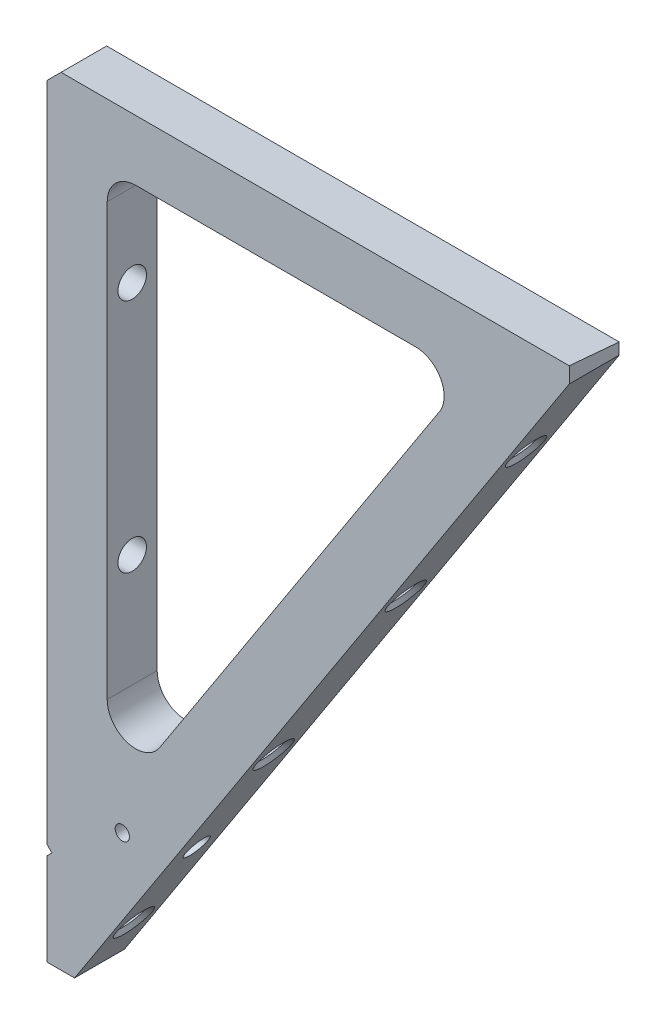
from build123d import *

# Parameters (mm, degrees)
BOSS_EXTRUDE1_DEPTH              = 11.1252
F_1_4_20_TAPPED_HOLE1_AT_2_COUNT = 2
F_1_4_20_TAPPED_HOLE1_AT_2_PITCH = 101.6
F_1_4_20_TAPPED_HOLE1_AT_3_COUNT = 2
F_1_4_20_TAPPED_HOLE1_AT_3_PITCH = 49.130736385
F_1_4_20_TAPPED_HOLE2_AT_2_COUNT = 2
F_1_4_20_TAPPED_HOLE2_AT_2_PITCH = 53.975
F_1_4_20_TAPPED_HOLE2_AT_3_COUNT = 2
F_1_4_20_TAPPED_HOLE2_AT_3_PITCH = 111.125
F_1_4_20_TAPPED_HOLE2_AT_4_COUNT = 2
F_1_4_20_TAPPED_HOLE2_AT_4_PITCH = 49.1998
CUT_EXTRUDE1_DEPTH               = 12.1252001
CHAMFER3_SIZE                    = 3.175
CUT_EXTRUDE2_DEPTH               = 119.608154476
CUT_EXTRUDE3_DEPTH               = 12.1252001
F_1_8_0_125_DIAMETER_HOLE1_D     = 3.175
CUT_EXTRUDE4_DEPTH               = 12.1252001


with BuildPart() as part:
    # Sketch1 → Boss-Extrude1 (new body)
    with BuildSketch(Plane.XY):
        Polygon((0, 0), (0, -182.6405415), (118.608154476, 0), align=None)
        with BuildLine():
            Line((19.802154476, -13.462), (82.118989682, -13.462))
            ThreePointArc((82.118989682, -13.462), (87.699478347, -16.782041872), (87.444547788, -23.270457872))
            Line((87.444547788, -23.270457872), (25.127712583, -119.229969062))
            ThreePointArc((25.127712583, -119.229969062), (17.998657037, -121.860016506), (13.452154476, -115.771511189))
            Line((13.452154476, -115.771511189), (13.452154476, -19.812))
            ThreePointArc((13.452154476, -19.812), (15.312026416, -15.321871939), (19.802154476, -13.462))
        make_face(mode=Mode.SUBTRACT)
    extrude(amount=BOSS_EXTRUDE1_DEPTH)

    # Sketch3 → 1/4-20 Tapped Hole1 (revolve, cut)
    with BuildSketch(Plane(origin=(0, -139.805902277, 5.5626), x_dir=(0, 0, 1), z_dir=(0, 1, 0))):
        Polygon((0, 0), (0, 32.217016902), (2.5527, 30.6832), (2.5527, 15.24), (3.175, 15.24), (3.175, 0.889), (4.064, 0), align=None)
    f_1_4_20_tapped_hole1 = revolve(axis=Axis((-6.35, -139.805902277, 5.5626), (1, 0, 0)), mode=Mode.SUBTRACT)

    # 1/4-20 Tapped Hole1 at 2: 1/4-20 Tapped Hole1 ×2
    with Locations(*[(0, i * F_1_4_20_TAPPED_HOLE1_AT_2_PITCH, 0) for i in range(1, F_1_4_20_TAPPED_HOLE1_AT_2_COUNT)]):
        add(f_1_4_20_tapped_hole1, mode=Mode.SUBTRACT)

    # 1/4-20 Tapped Hole1 at 3: 1/4-20 Tapped Hole1 ×2
    with Locations(*[(0, i * F_1_4_20_TAPPED_HOLE1_AT_3_PITCH, 0) for i in range(1, F_1_4_20_TAPPED_HOLE1_AT_3_COUNT)]):
        add(f_1_4_20_tapped_hole1, mode=Mode.SUBTRACT)

    # Sketch6 → 1/4-20 Tapped Hole2 (revolve, cut)
    with BuildSketch(Plane(origin=(74.349919226, -68.151705822, 5.5626), x_dir=(0.544639035, 0.838670568, 0), z_dir=(0, 0, 1))):
        Polygon((0, 0), (0, 19.517016902), (2.5527, 17.9832), (2.5527, 15.24), (3.175, 15.24), (3.175, 0.889), (4.064, 0), align=None)
    f_1_4_20_tapped_hole2 = revolve(axis=Axis((79.675477332, -71.610163694, 5.5626), (-0.838670568, 0.544639035, 0)), mode=Mode.SUBTRACT)

    # 1/4-20 Tapped Hole2 at 2: 1/4-20 Tapped Hole2 ×2
    with Locations(*[Vector(-0.544639035, -0.838670568, 0) * (i * F_1_4_20_TAPPED_HOLE2_AT_2_PITCH) for i in range(1, F_1_4_20_TAPPED_HOLE2_AT_2_COUNT)]):
        add(f_1_4_20_tapped_hole2, mode=Mode.SUBTRACT)

    # 1/4-20 Tapped Hole2 at 3: 1/4-20 Tapped Hole2 ×2
    with Locations(*[Vector(-0.544639035, -0.838670568, 0) * (i * F_1_4_20_TAPPED_HOLE2_AT_3_PITCH) for i in range(1, F_1_4_20_TAPPED_HOLE2_AT_3_COUNT)]):
        add(f_1_4_20_tapped_hole2, mode=Mode.SUBTRACT)

    # 1/4-20 Tapped Hole2 at 4: 1/4-20 Tapped Hole2 ×2
    with Locations(*[Vector(0.544639035, 0.838670568, 0) * (i * F_1_4_20_TAPPED_HOLE2_AT_4_PITCH) for i in range(1, F_1_4_20_TAPPED_HOLE2_AT_4_COUNT)]):
        add(f_1_4_20_tapped_hole2, mode=Mode.SUBTRACT)

    # Sketch8 → Cut-Extrude1 (cut, through all)
    with BuildSketch(Plane.XY.offset(11.1252)):
        Polygon((0, -182.6405415), (0, -173.1155415), (6.185607325, -173.1155415), align=None)
    extrude(amount=-CUT_EXTRUDE1_DEPTH, mode=Mode.SUBTRACT)

    # Chamfer3
    chamfer3_edges = [part.edges().sort_by_distance(p)[0] for p in [
        (0, 0, 5.5626),
    ]]
    chamfer(chamfer3_edges, length=CHAMFER3_SIZE)

    # Sketch9 → Cut-Extrude2 (cut, through all)
    with BuildSketch(Plane.ZY):
        Polygon((11.1252, 0), (0, 0), (0, -0.973328879), align=None)
    extrude(amount=-CUT_EXTRUDE2_DEPTH, mode=Mode.SUBTRACT)

    # Sketch10 → Cut-Extrude3 (cut, through all)
    with BuildSketch(Plane.XY.offset(11.1252)):
        Polygon((118.608154476, 0), (116.322154476, 0), (116.322154476, -3.520131307), align=None)
    extrude(amount=-CUT_EXTRUDE3_DEPTH, mode=Mode.SUBTRACT)

    # 1/8 (0.125) Diameter Hole1 (through all)
    with Locations(Plane.XY.offset(11.1252)):
        with Locations((16.8148, -139.805902277)):
            Hole(F_1_8_0_125_DIAMETER_HOLE1_D / 2)

    # Sketch14 → Cut-Extrude4 (cut, through all)
    with BuildSketch(Plane.XY.offset(11.1252)):
        Polygon((0, -150.3825415), (0, -152.6685415), (1.143, -151.5255415), align=None)
    extrude(amount=-CUT_EXTRUDE4_DEPTH, mode=Mode.SUBTRACT)


solid = part.part
